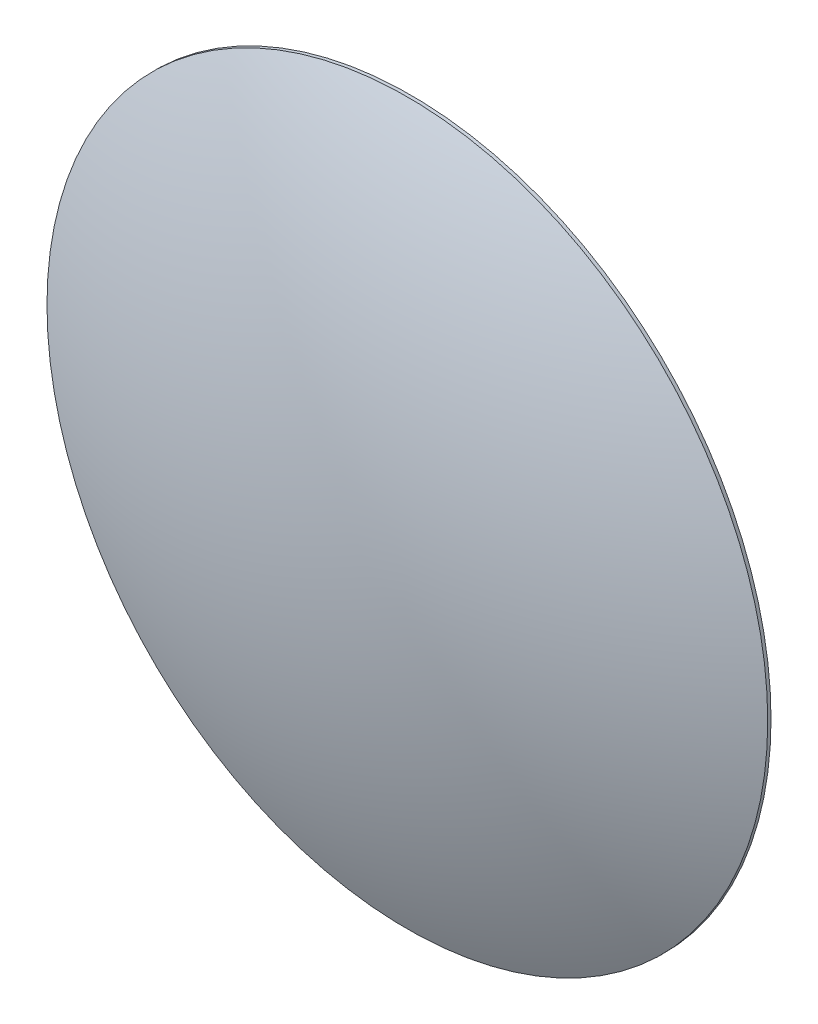
from build123d import *

# Parameters (mm, degrees)
ESQUISSE1_R       = 11
EXTRUSION2_DEPTH  = 0.1
D_ME2_FACE_RADIUS = 11
D_ME2_HEIGHT      = 2.4


with BuildPart() as part:
    # Esquisse1 → Extrusion2 (new body)
    with BuildSketch(Plane.XY):
        Circle(ESQUISSE1_R)
    extrude(amount=EXTRUSION2_DEPTH)

    # D_me2: a dome of height H over a round flat face of radius A is a cap of a sphere of radius (A * A + H * H) / (2 * H)
    d_me2_r = (D_ME2_FACE_RADIUS * D_ME2_FACE_RADIUS + D_ME2_HEIGHT * D_ME2_HEIGHT) / (2 * D_ME2_HEIGHT)
    d_me2_base = Plane((0, 0, 0.1), z_dir=(0, 0, 1))
    with Locations(d_me2_base.offset(D_ME2_HEIGHT - d_me2_r)):
        d_me2_ball = Sphere(d_me2_r, mode=Mode.PRIVATE)
    add(split(d_me2_ball, bisect_by=d_me2_base, keep=Keep.TOP, mode=Mode.PRIVATE))


solid = part.part
